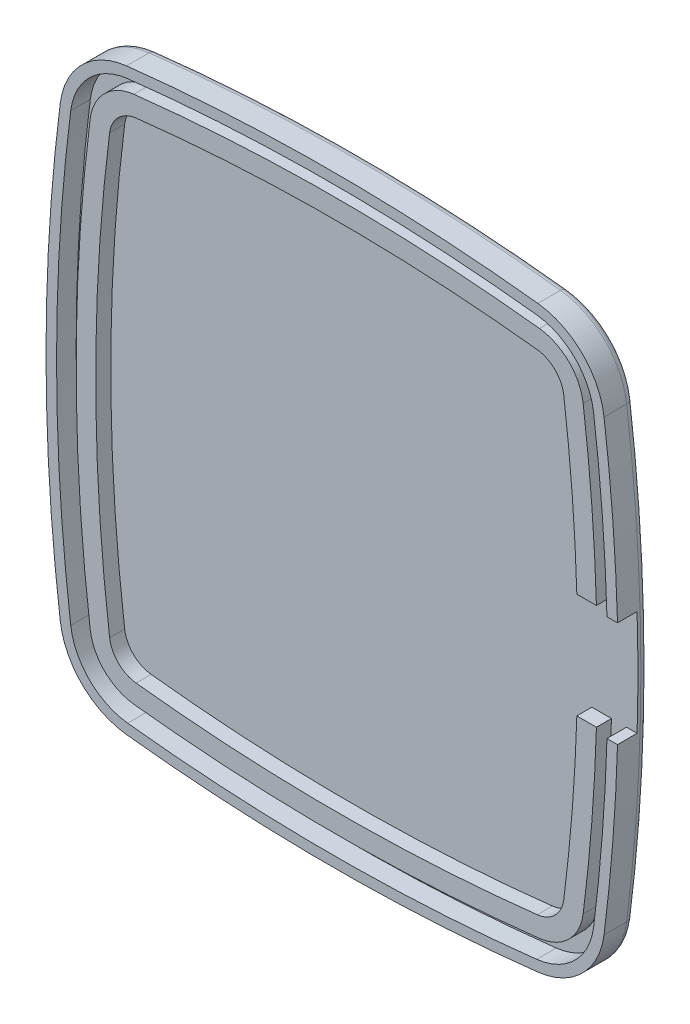
from build123d import *

# Parameters (mm, degrees)
IZIM1_W                      = 38
IZIM1_H                      = 40
Y_KSEKLIK_EKSTR_ZYON1_DEPTH  = 1
KES_EKSTR_ZYON1_DEPTH        = 3
KES_EKSTR_ZYON2_DEPTH        = 3
RADYUS1_R                    = 5
RADYUS2_R                    = 0.5
BO_ALTMA1_T                  = -0.7
Y_KSEKLIK_EKSTR_ZYON10_DEPTH = 1
IZIM11_W                     = 8.743139336
IZIM11_H                     = 7
KES_EKSTR_ZYON3_DEPTH        = 10


with BuildPart() as part:
    # Çizim1 → Yükseklik-Ekstrüzyon1 (new body, symmetric)
    with BuildSketch(Plane.XY):
        Rectangle(IZIM1_W, IZIM1_H)
    extrude(amount=Y_KSEKLIK_EKSTR_ZYON1_DEPTH, both=True)

    # Çizim2 → Kes-Ekstrüzyon1 (cut, through all)
    with BuildSketch(Plane.XY.offset(1)):
        with BuildLine():
            Line((19, 20), (-3.93e-07, 20))
            ThreePointArc((-3.93e-07, 20), (9.52955908, 19.624417515), (19, 18.5))
            Line((19, 18.5), (19, 20))
        make_face()
        with BuildLine():
            Line((-3.93e-07, 20), (-19, 20))
            Line((-19, 20), (-19, 18.5))
            ThreePointArc((-19, 18.5), (-9.529559472, 19.624417484), (-3.93e-07, 20))
        make_face()
        with BuildLine():
            ThreePointArc((-3.93e-07, -20), (-9.529559472, -19.624417484), (-19, -18.5))
            Line((-19, -18.5), (-19, -20))
            Line((-19, -20), (-3.93e-07, -20))
        make_face()
        with BuildLine():
            Line((19, -20), (19, -18.5))
            ThreePointArc((19, -18.5), (9.52955908, -19.624417515), (-3.93e-07, -20))
            Line((-3.93e-07, -20), (19, -20))
        make_face()
    extrude(amount=-KES_EKSTR_ZYON1_DEPTH, mode=Mode.SUBTRACT)

    # Çizim3 → Kes-Ekstrüzyon2 (cut, through all)
    with BuildSketch(Plane.XY.offset(1)):
        with BuildLine():
            Line((19, 0), (19, 18.5))
            ThreePointArc((19, 18.5), (18.250358245, 18.61670023), (17.5, 18.728701167))
            ThreePointArc((17.5, 18.728701167), (18.624400556, 9.39433669), (19, 0))
        make_face()
        with BuildLine():
            Line((19, -18.5), (19, 0))
            ThreePointArc((19, 0), (18.624400556, -9.39433669), (17.5, -18.728701167))
            ThreePointArc((17.5, -18.728701167), (18.250358245, -18.61670023), (19, -18.5))
        make_face()
        with BuildLine():
            ThreePointArc((-19, -18.5), (-18.250358245, -18.61670023), (-17.5, -18.728701167))
            ThreePointArc((-17.5, -18.728701167), (-18.624400576, -9.394336436), (-19, 5.11e-07))
            Line((-19, 5.11e-07), (-19, -18.5))
        make_face()
        with BuildLine():
            ThreePointArc((-19, 5.11e-07), (-18.624400535, 9.394336945), (-17.5, 18.728701167))
            ThreePointArc((-17.5, 18.728701167), (-18.250358245, 18.61670023), (-19, 18.5))
            Line((-19, 18.5), (-19, 5.11e-07))
        make_face()
    extrude(amount=-KES_EKSTR_ZYON2_DEPTH, mode=Mode.SUBTRACT)

    # Radyus1
    radyus1_edges = [part.edges().sort_by_distance(p)[0] for p in [
        (17.5, 18.728701167, 0),
        (17.5, -18.728701167, 0),
        (-17.5, -18.728701167, 0),
        (-17.5, 18.728701167, 0),
    ]]
    fillet(radyus1_edges, radius=RADYUS1_R)

    # Radyus2
    radyus2_edges = [part.edges().sort_by_distance(p)[0] for p in [
        (-19, 0, -1),
        (0, -20, -1),
        (0, 20, -1),
        (19, 0, -1),
        (16.605030449, 17.819079797, -1),
        (-16.605030449, 17.819079797, -1),
        (16.605030449, -17.819079797, -1),
        (-16.605030449, -17.819079797, -1),
    ]]
    fillet(radyus2_edges, radius=RADYUS2_R)

    # İç Boşaltma1
    bo_altma1_openings = [part.faces().sort_by_distance(p)[0] for p in [
        (0, 0, 1),
    ]]
    offset(amount=BO_ALTMA1_T, openings=bo_altma1_openings)


with BuildPart() as body_2:
    # Çizim10 → Yükseklik-Ekstrüzyon10 (new body)
    with BuildSketch(Plane.XY.offset(-0.3)):
        with BuildLine():
            ThreePointArc((13.466311515, 17.538075915), (0, 18.3), (-13.466311515, 17.538075915))
            ThreePointArc((-13.466311515, 17.538075915), (-15.411305619, 16.608699266), (-16.367541698, 14.676768734))
            ThreePointArc((-16.367541698, 14.676768734), (-17.3, 0), (-16.367541698, -14.676768734))
            ThreePointArc((-16.367541698, -14.676768734), (-15.411305619, -16.608699266), (-13.466311515, -17.538075915))
            ThreePointArc((-13.466311515, -17.538075915), (0, -18.3), (13.466311515, -17.538075915))
            ThreePointArc((13.466311515, -17.538075915), (15.411305619, -16.608699266), (16.367541698, -14.676768734))
            ThreePointArc((16.367541698, -14.676768734), (17.3, 0), (16.367541698, 14.676768734))
            ThreePointArc((16.367541698, 14.676768734), (15.411305619, 16.608699266), (13.466311515, 17.538075915))
        make_face()
        with BuildLine():
            ThreePointArc((13.319672915, 16.246372729), (0, 17), (-13.319672915, 16.246372729))
            ThreePointArc((-13.319672915, 16.246372729), (-14.49845722, 15.683114154), (-15.077994237, 14.512247165))
            ThreePointArc((-15.077994237, 14.512247165), (-16, 0), (-15.077994237, -14.512247165))
            ThreePointArc((-15.077994237, -14.512247165), (-14.49845722, -15.683114154), (-13.319672915, -16.246372729))
            ThreePointArc((-13.319672915, -16.246372729), (0, -17), (13.319672915, -16.246372729))
            ThreePointArc((13.319672915, -16.246372729), (14.49845722, -15.683114154), (15.077994237, -14.512247165))
            ThreePointArc((15.077994237, -14.512247165), (16, 0), (15.077994237, 14.512247165))
            ThreePointArc((15.077994237, 14.512247165), (14.49845722, 15.683114154), (13.319672915, 16.246372729))
        make_face(mode=Mode.SUBTRACT)
    extrude(amount=Y_KSEKLIK_EKSTR_ZYON10_DEPTH)


with BuildPart() as kes_ekstr_zyon3_tool:
    # Çizim11 → Kes-Ekstrüzyon3 (new body)
    with BuildSketch(Plane.XY.offset(-0.3)):
        with Locations((16.993814773, 0)):
            Rectangle(IZIM11_W, IZIM11_H)
    extrude(amount=KES_EKSTR_ZYON3_DEPTH)


with BuildPart() as part_1:
    add(part.part)

    # Kes-Ekstrüzyon3: cut by kes_ekstr_zyon3_tool
    add(kes_ekstr_zyon3_tool.part, mode=Mode.SUBTRACT)


with BuildPart() as body_2_1:
    add(body_2.part)

    # Kes-Ekstrüzyon3: cut by kes_ekstr_zyon3_tool
    add(kes_ekstr_zyon3_tool.part, mode=Mode.SUBTRACT)


solid = Compound([part_1.part, body_2_1.part])
